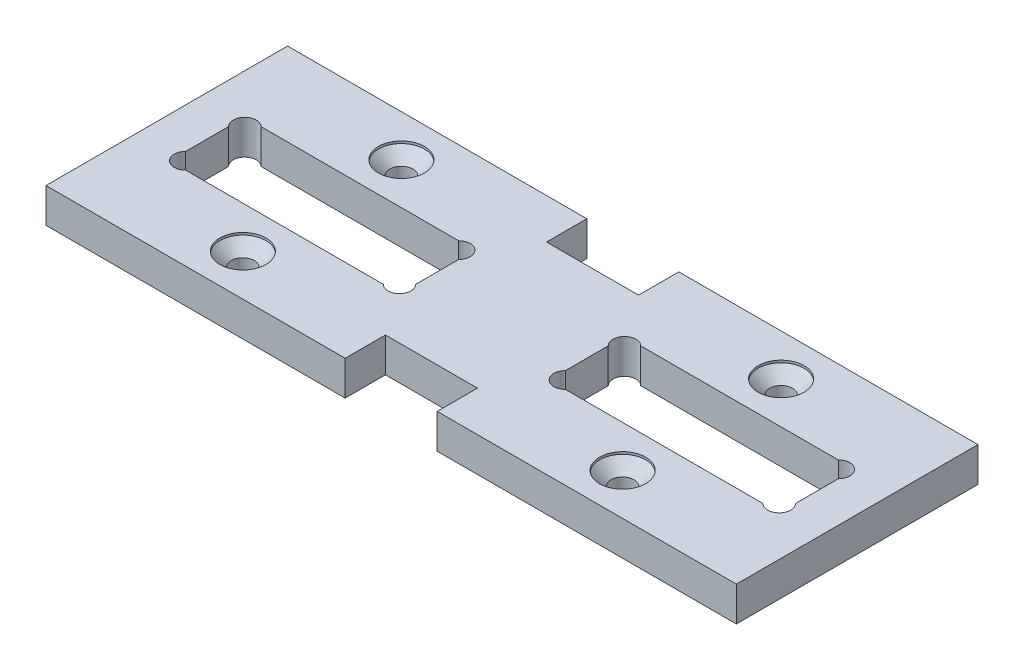
from build123d import *

# Parameters (mm, degrees)
SKETCH1_R                                      = 1
BOSS_EXTRUDE1_DEPTH                            = 3
CSK_FOR_M2_FLAT_HEAD_MACHINE_SCREW1_AT_2_COUNT = 2
CSK_FOR_M2_FLAT_HEAD_MACHINE_SCREW1_AT_2_PITCH = 13.775
CSK_FOR_M2_FLAT_HEAD_MACHINE_SCREW1_AT_3_COUNT = 2
CSK_FOR_M2_FLAT_HEAD_MACHINE_SCREW1_AT_3_PITCH = 33
CSK_FOR_M2_FLAT_HEAD_MACHINE_SCREW1_AT_4_COUNT = 2
CSK_FOR_M2_FLAT_HEAD_MACHINE_SCREW1_AT_4_PITCH = 35.759622831


with BuildPart() as part:
    # Sketch1 → Boss-Extrude1 (new body)
    with BuildSketch(Plane(origin=(0, 0, 0), x_dir=(1, 0, 0), z_dir=(0, 1, 0))):
        Polygon((-30, 10.5), (-30, -10.5), (-4, -10.5), (-4, -7), (4, -7), (4, -10.5), (30, -10.5), (30, 10.5), (4, 10.5), (4, 7), (-4, 7), (-4, 10.5), align=None)
        with Locations((16.5, -6.8875)):
            Circle(SKETCH1_R, mode=Mode.SUBTRACT)
        with Locations((-16.5, -6.8875)):
            Circle(SKETCH1_R, mode=Mode.SUBTRACT)
        with Locations((-16.5, 6.8875)):
            Circle(SKETCH1_R, mode=Mode.SUBTRACT)
        with BuildLine():
            Line((-25.085786438, 3.275), (-7.914213562, 3.275))
            ThreePointArc((-7.914213562, 3.275), (-6.5, 3.275), (-6.5, 1.860786438))
            Line((-6.5, 1.860786438), (-6.5, -1.860786438))
            ThreePointArc((-6.5, -1.860786438), (-6.5, -3.275), (-7.914213562, -3.275))
            Line((-7.914213562, -3.275), (-25.085786438, -3.275))
            ThreePointArc((-25.085786438, -3.275), (-26.5, -3.275), (-26.5, -1.860786438))
            Line((-26.5, -1.860786438), (-26.5, 1.860786438))
            ThreePointArc((-26.5, 1.860786438), (-26.5, 3.275), (-25.085786438, 3.275))
        make_face(mode=Mode.SUBTRACT)
        with Locations((16.5, 6.8875)):
            Circle(SKETCH1_R, mode=Mode.SUBTRACT)
        with BuildLine():
            Line((26.5, 1.860786438), (26.5, -1.860786438))
            ThreePointArc((26.5, -1.860786438), (26.5, -3.275), (25.085786438, -3.275))
            Line((25.085786438, -3.275), (7.914213562, -3.275))
            ThreePointArc((7.914213562, -3.275), (6.5, -3.275), (6.5, -1.860786438))
            Line((6.5, -1.860786438), (6.5, 1.860786438))
            ThreePointArc((6.5, 1.860786438), (6.5, 3.275), (7.914213562, 3.275))
            Line((7.914213562, 3.275), (25.085786438, 3.275))
            ThreePointArc((25.085786438, 3.275), (26.5, 3.275), (26.5, 1.860786438))
        make_face(mode=Mode.SUBTRACT)
    extrude(amount=BOSS_EXTRUDE1_DEPTH)

    # Sketch3 → CSK for M2 Flat Head Machine Screw1 (revolve, cut)
    with BuildSketch(Plane(origin=(-16.5, 3, -6.8875), x_dir=(0, 0, 1), z_dir=(1, 0, 0))):
        Polygon((0, 0), (0, 3), (1, 3), (1, 1.2), (2, 0.2), (2, 0), align=None)
    csk_for_m2_flat_head_machine_screw1 = revolve(axis=Axis((-16.5, 9.35, -6.8875), (0, -1, 0)), mode=Mode.SUBTRACT)

    # CSK for M2 Flat Head Machine Screw1 at 2: CSK for M2 Flat Head Machine Screw1 ×2
    with Locations(*[(0, 0, i * CSK_FOR_M2_FLAT_HEAD_MACHINE_SCREW1_AT_2_PITCH) for i in range(1, CSK_FOR_M2_FLAT_HEAD_MACHINE_SCREW1_AT_2_COUNT)]):
        add(csk_for_m2_flat_head_machine_screw1, mode=Mode.SUBTRACT)

    # CSK for M2 Flat Head Machine Screw1 at 3: CSK for M2 Flat Head Machine Screw1 ×2
    with Locations(*[(i * CSK_FOR_M2_FLAT_HEAD_MACHINE_SCREW1_AT_3_PITCH, 0, 0) for i in range(1, CSK_FOR_M2_FLAT_HEAD_MACHINE_SCREW1_AT_3_COUNT)]):
        add(csk_for_m2_flat_head_machine_screw1, mode=Mode.SUBTRACT)

    # CSK for M2 Flat Head Machine Screw1 at 4: CSK for M2 Flat Head Machine Screw1 ×2
    with Locations(*[Vector(0.922828525, 0, 0.385210998) * (i * CSK_FOR_M2_FLAT_HEAD_MACHINE_SCREW1_AT_4_PITCH) for i in range(1, CSK_FOR_M2_FLAT_HEAD_MACHINE_SCREW1_AT_4_COUNT)]):
        add(csk_for_m2_flat_head_machine_screw1, mode=Mode.SUBTRACT)


solid = part.part
